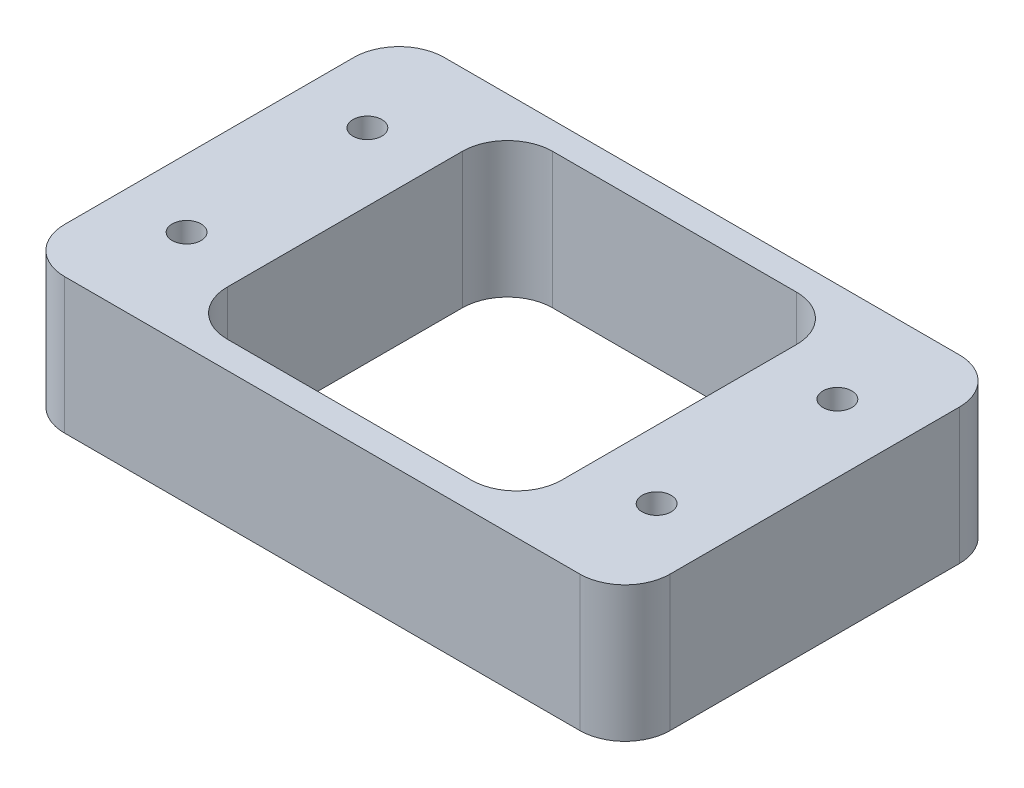
from build123d import *

# Parameters (mm, degrees)
SKETCH1_W           = 67
SKETCH1_H           = 42
SKETCH1_R           = 1.6
BOSS_EXTRUDE1_DEPTH = 15
SKETCH2_W           = 37
SKETCH2_H           = 36
CUT_EXTRUDE1_DEPTH  = 16
FILLET1_R           = 5


with BuildPart() as part:
    # Sketch1 → Boss-Extrude1 (new body)
    with BuildSketch(Plane(origin=(0, 0, 0), x_dir=(1, 0, 0), z_dir=(0, 1, 0))):
        with Locations((33.5, 21)):
            Rectangle(SKETCH1_W, SKETCH1_H)
        with Locations((7.5, 31)):
            Circle(SKETCH1_R, mode=Mode.SUBTRACT)
        with Locations((7.5, 11)):
            Circle(SKETCH1_R, mode=Mode.SUBTRACT)
        with Locations((59.5, 11)):
            Circle(SKETCH1_R, mode=Mode.SUBTRACT)
        with Locations((59.5, 31)):
            Circle(SKETCH1_R, mode=Mode.SUBTRACT)
    extrude(amount=BOSS_EXTRUDE1_DEPTH)

    # Sketch2 → Cut-Extrude1 (cut, through all)
    with BuildSketch(Plane(origin=(0, 15, 0), x_dir=(1, 0, 0), z_dir=(0, 1, 0))):
        with Locations((33.5, 21)):
            Rectangle(SKETCH2_W, SKETCH2_H)
    extrude(amount=-CUT_EXTRUDE1_DEPTH, mode=Mode.SUBTRACT)

    # Fillet1
    fillet1_edges = [part.edges().sort_by_distance(p)[0] for p in [
        (52, 7.5, -39),
        (52, 7.5, -3),
        (15, 7.5, -3),
        (15, 7.5, -39),
        (0, 7.5, -42),
        (67, 7.5, -42),
        (67, 7.5, 0),
        (0, 7.5, 0),
    ]]
    fillet(fillet1_edges, radius=FILLET1_R)


solid = part.part
